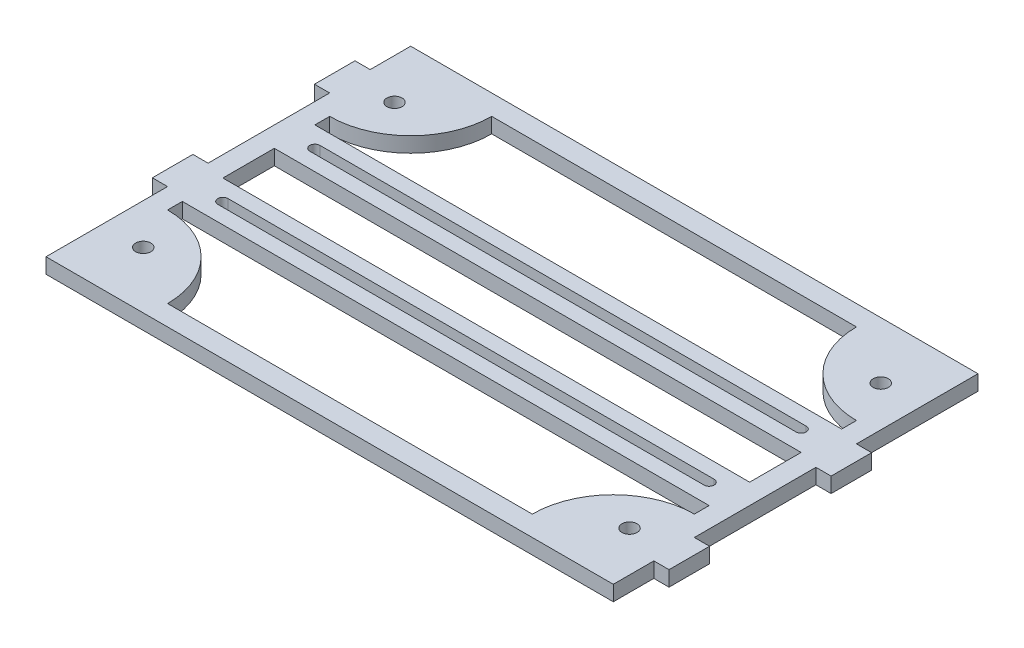
from build123d import *

# Parameters (mm, degrees)
SKETCH1_W           = 177.8
SKETCH1_H           = 114.3
SKETCH1_W_2         = 165.1
SKETCH1_H_2         = 16.134929366
BOSS_EXTRUDE1_DEPTH = 4.7625
CUT_EXTRUDE1_DEPTH  = 5.7625
SKETCH4_R           = 2.38125
CUT_EXTRUDE2_DEPTH  = 5.7625
SKETCH7_W           = 12.7
SKETCH7_H           = 4.7625
BOSS_EXTRUDE2_DEPTH = 4.7625
SKETCH8_W           = 12.7
SKETCH8_H           = 4.7625
BOSS_EXTRUDE3_DEPTH = 4.7625


with BuildPart() as part:
    # Sketch1 → Boss-Extrude1 (new body)
    with BuildSketch(Plane(origin=(0, 0, 0), x_dir=(1, 0, 0), z_dir=(0, 1, 0))):
        Rectangle(SKETCH1_W, SKETCH1_H)
        with BuildLine():
            Line((-82.55, -25.4), (-82.55, -20.767464683))
            Line((-82.55, -20.767464683), (82.55, -20.767464683))
            Line((82.55, -20.767464683), (82.55, -25.4))
            ThreePointArc((82.55, -25.4), (64.589487758, -32.839487758), (57.15, -50.8))
            Line((57.15, -50.8), (-57.15, -50.8))
            ThreePointArc((-57.15, -50.8), (-64.589487758, -32.839487758), (-82.55, -25.4))
        make_face(mode=Mode.SUBTRACT)
        Rectangle(SKETCH1_W_2, SKETCH1_H_2, mode=Mode.SUBTRACT)
        with BuildLine():
            Line((82.55, 20.767464683), (-82.55, 20.767464683))
            Line((-82.55, 20.767464683), (-82.55, 25.4))
            ThreePointArc((-82.55, 25.4), (-64.589487758, 32.839487758), (-57.15, 50.8))
            Line((-57.15, 50.8), (57.15, 50.8))
            ThreePointArc((57.15, 50.8), (64.589487758, 32.839487758), (82.55, 25.4))
            Line((82.55, 25.4), (82.55, 20.767464683))
        make_face(mode=Mode.SUBTRACT)
    extrude(amount=BOSS_EXTRUDE1_DEPTH)

    # Sketch3 → Cut-Extrude1 (cut, through all)
    with BuildSketch(Plane(origin=(0, 4.7625, 0), x_dir=(1, 0, 0), z_dir=(0, 1, 0))):
        with BuildLine():
            Line((-76.2, 16.004964683), (76.2, 16.004964683))
            ThreePointArc((76.2, 16.004964683), (77.7875, 14.417464683), (76.2, 12.829964683))
            Line((76.2, 12.829964683), (-76.2, 12.829964683))
            ThreePointArc((-76.2, 12.829964683), (-77.7875, 14.417464683), (-76.2, 16.004964683))
        make_face()
        with BuildLine():
            Line((-76.2, -16.004964683), (76.2, -16.004964683))
            ThreePointArc((76.2, -16.004964683), (77.7875, -14.417464683), (76.2, -12.829964683))
            Line((76.2, -12.829964683), (-76.2, -12.829964683))
            ThreePointArc((-76.2, -12.829964683), (-77.7875, -14.417464683), (-76.2, -16.004964683))
        make_face()
    extrude(amount=-CUT_EXTRUDE1_DEPTH, mode=Mode.SUBTRACT)

    # Sketch4 → Cut-Extrude2 (cut, through all)
    with BuildSketch(Plane(origin=(0, 4.7625, 0), x_dir=(1, 0, 0), z_dir=(0, 1, 0))):
        with Locations((-76.2, 39.37)):
            Circle(SKETCH4_R)
        with Locations((-76.2, -39.37)):
            Circle(SKETCH4_R)
        with Locations((76.2, -39.37)):
            Circle(SKETCH4_R)
        with Locations((76.2, 39.37)):
            Circle(SKETCH4_R)
    extrude(amount=-CUT_EXTRUDE2_DEPTH, mode=Mode.SUBTRACT)

    # Sketch7 → Boss-Extrude2 (add)
    with BuildSketch(Plane(origin=(88.9, 0, 0), x_dir=(0, 0, -1), z_dir=(1, 0, 0))):
        with Locations((-38.1, 2.38125)):
            Rectangle(SKETCH7_W, SKETCH7_H)
        with Locations((12.7, 2.38125)):
            Rectangle(SKETCH7_W, SKETCH7_H)
    extrude(amount=BOSS_EXTRUDE2_DEPTH)

    # Sketch8 → Boss-Extrude3 (add)
    with BuildSketch(Plane.ZY.offset(88.9)):
        with Locations((-38.1, 2.38125)):
            Rectangle(SKETCH8_W, SKETCH8_H)
        with Locations((12.7, 2.38125)):
            Rectangle(SKETCH8_W, SKETCH8_H)
    extrude(amount=BOSS_EXTRUDE3_DEPTH)


solid = part.part
